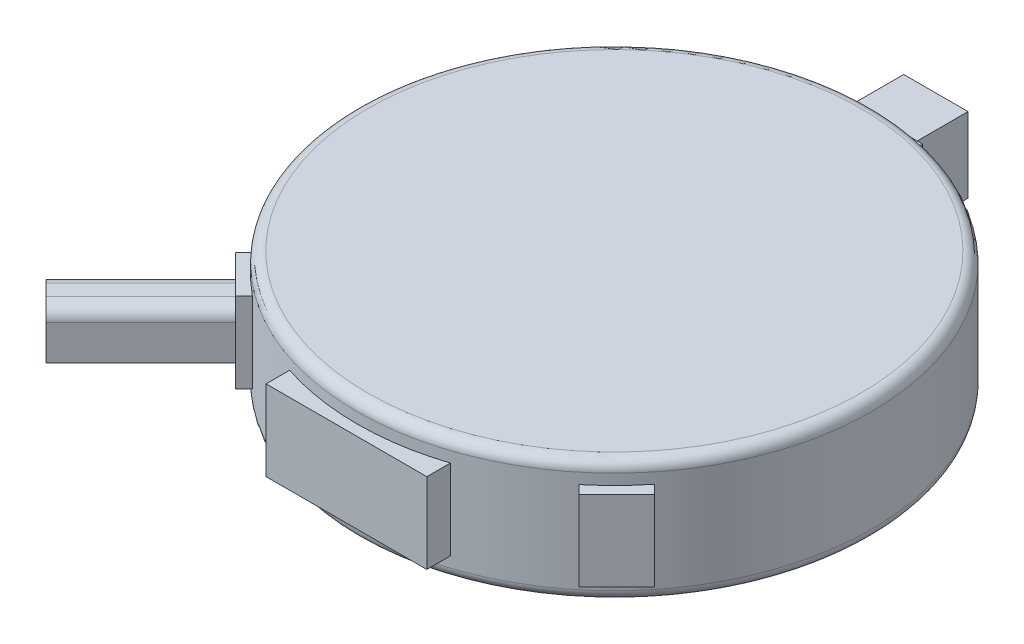
from build123d import *

# Parameters (mm, degrees)
EXTRUSION1_DEPTH      = 15
ESQUISSE2_R           = 48
EXTRUSION2_DEPTH      = 4
EXTRUSION2_DEPTH_BACK = 19
CONG_1_R              = 2
EXTRUSION5_DEPTH      = 25
ESQUISSE6_W           = 12
ESQUISSE6_H           = 14
ESQUISSE6_W_2         = 10
ESQUISSE6_H_2         = 12
EXTRUSION6_DEPTH      = 10


with BuildPart() as part:
    # Esquisse1 → Extrusion1 (new body)
    with BuildSketch(Plane(origin=(0, 0, 0), x_dir=(1, 0, 0), z_dir=(0, 1, 0))):
        Polygon((-7.5, 100), (7.5, 100), (7.5, 50), (39.104688576, 18.395311424), (32.033620764, 11.324243612), (15, 28.357864376), (15, 0), (-15, 0), (-15, 28.357864376), (-32.033620764, 11.324243612), (-39.104688576, 18.395311424), (-7.5, 50), align=None)
    extrude(amount=EXTRUSION1_DEPTH)

    # Esquisse2 → Extrusion2 (add, two sides)
    with BuildSketch(Plane(origin=(0, 15, 0), x_dir=(1, 0, 0), z_dir=(0, 1, 0))) as extrusion2_sk:
        with Locations((0, 50)):
            Circle(ESQUISSE2_R)
    extrude(amount=EXTRUSION2_DEPTH)
    extrude(extrusion2_sk.sketch, amount=-EXTRUSION2_DEPTH_BACK)

    # Congé1
    cong_1_edges = [part.edges().sort_by_distance(p)[0] for p in [
        (-48, -4, -50),
        (-48, 19, -50),
    ]]
    fillet(cong_1_edges, radius=CONG_1_R)

    # Esquisse5 → Extrusion5 (add)
    with BuildSketch(Plane(origin=(-10.354688576, 0, 10.354688576), x_dir=(0.707106781, 0, 0.707106781), z_dir=(-0.707106781, 0, 0.707106781))):
        with BuildLine():
            Line((-39.658639918, 3.5), (-39.658639918, 10))
            ThreePointArc((-39.658639918, 10), (-38.926406871, 11.767766953), (-37.158639918, 12.5))
            Line((-37.158639918, 12.5), (-34.158639918, 12.5))
            ThreePointArc((-34.158639918, 12.5), (-32.390872965, 11.767766953), (-31.658639918, 10))
            Line((-31.658639918, 10), (-31.658639918, 3.5))
            Line((-31.658639918, 3.5), (-39.658639918, 3.5))
        make_face()
        with BuildLine():
            Line((-37.658639918, 10), (-37.658639918, 5.5))
            Line((-37.658639918, 5.5), (-33.658639918, 5.5))
            Line((-33.658639918, 5.5), (-33.658639918, 10))
            ThreePointArc((-33.658639918, 10), (-33.805086528, 10.353553391), (-34.158639918, 10.5))
            Line((-34.158639918, 10.5), (-37.158639918, 10.5))
            ThreePointArc((-37.158639918, 10.5), (-37.512193309, 10.353553391), (-37.658639918, 10))
        make_face(mode=Mode.SUBTRACT)
    extrude(amount=EXTRUSION5_DEPTH)

    # Esquisse6 → Extrusion6 (add)
    with BuildSketch(Plane(origin=(0, 0, -100), x_dir=(-1, 0, 0), z_dir=(0, 0, -1))):
        with Locations((0, 7.5)):
            Rectangle(ESQUISSE6_W, ESQUISSE6_H)
        with Locations((0, 7.5)):
            Rectangle(ESQUISSE6_W_2, ESQUISSE6_H_2, mode=Mode.SUBTRACT)
    extrude(amount=EXTRUSION6_DEPTH)


solid = part.part
